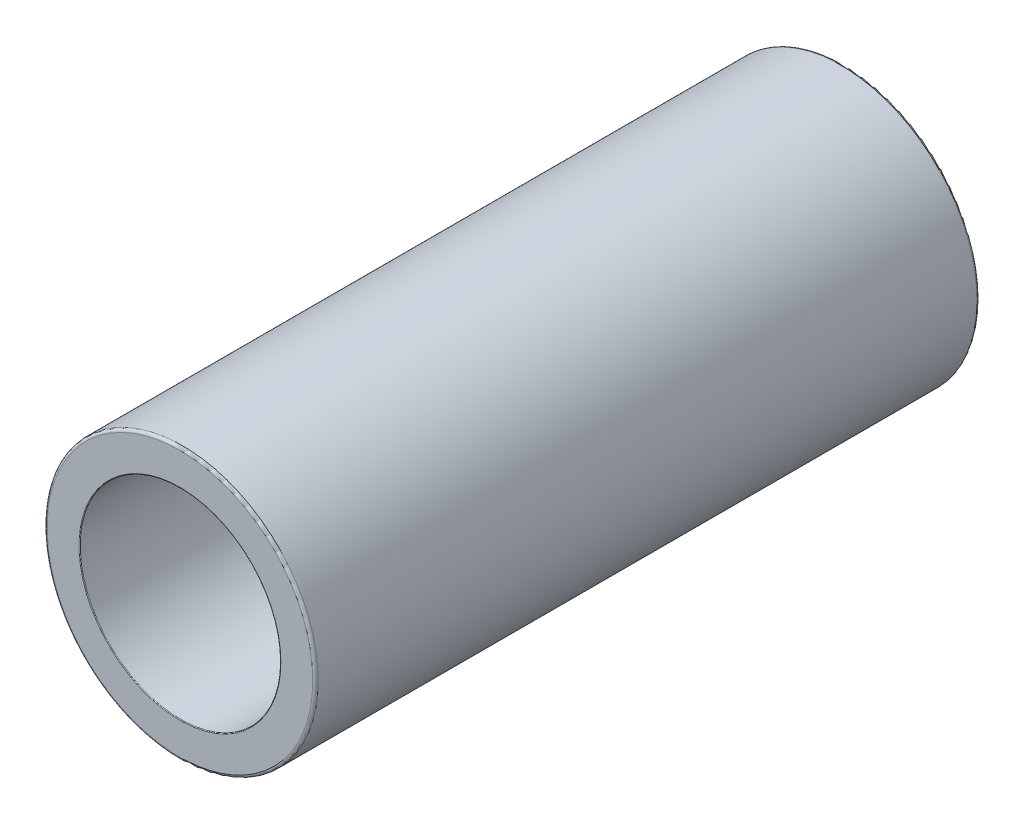
from build123d import *

# Parameters (mm, degrees)
SCHIZZO1_R                   = 10
SCHIZZO1_R_2                 = 7.4
ESTRUSIONE_ESTRUSIONE1_DEPTH = 49
RACCORDO1_R                  = 0.2
RACCORDO2_R                  = 0.05


with BuildPart() as part:
    # Schizzo1 → Estrusione-Estrusione1 (new body)
    with BuildSketch(Plane.XY):
        Circle(SCHIZZO1_R)
        Circle(SCHIZZO1_R_2, mode=Mode.SUBTRACT)
    extrude(amount=ESTRUSIONE_ESTRUSIONE1_DEPTH)

    # Raccordo1
    raccordo1_edges = [part.edges().sort_by_distance(p)[0] for p in [
        (-10, 0, 0),
        (-10, 0, 49),
    ]]
    fillet(raccordo1_edges, radius=RACCORDO1_R)

    # Raccordo2
    raccordo2_edges = [part.edges().sort_by_distance(p)[0] for p in [
        (-7.4, 0, 0),
        (-7.4, 0, 49),
    ]]
    fillet(raccordo2_edges, radius=RACCORDO2_R)


solid = part.part
